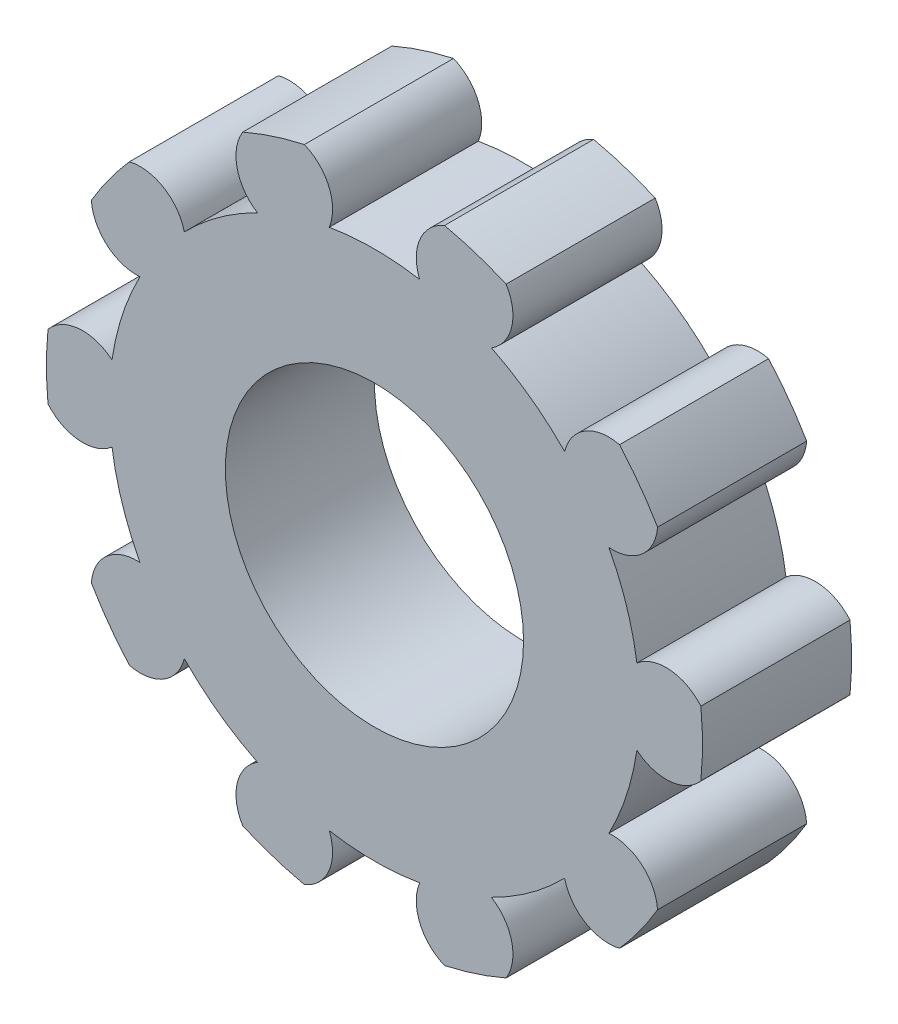
from build123d import *

# Parameters (mm, degrees)
SKETCH1_R           = 13.2
SKETCH1_R_2         = 6
BOSS_EXTRUDE1_DEPTH = 6
CUT_EXTRUDE1_DEPTH  = 7
CIRPATTERN1_COUNT   = 10


with BuildPart() as part:
    # Sketch1 → Boss-Extrude1 (new body)
    with BuildSketch(Plane.XY):
        Circle(SKETCH1_R)
        Circle(SKETCH1_R_2, mode=Mode.SUBTRACT)
    extrude(amount=BOSS_EXTRUDE1_DEPTH)

    # Sketch2 → Cut-Extrude1 (cut, through all)
    with BuildSketch(Plane.XY.offset(6)):
        with BuildLine():
            ThreePointArc((-2.819851171, 12.895287487), (0, 13.2), (2.819851171, 12.895287487))
            ThreePointArc((2.819851171, 12.895287487), (1.826256171, 11.910750525), (1.819851171, 10.512))
            ThreePointArc((1.819851171, 10.512), (0, 10.668364555), (-1.819851171, 10.512))
            ThreePointArc((-1.819851171, 10.512), (-1.826256171, 11.910750525), (-2.819851171, 12.895287487))
        make_face()
    cut_extrude1 = extrude(amount=-CUT_EXTRUDE1_DEPTH, mode=Mode.SUBTRACT)

    # CirPattern1: Cut-Extrude1 ×10 about axis
    cirpattern1_axis = Axis((0, 0, 0), (0, 0, 1))
    for i in range(1, CIRPATTERN1_COUNT):
        add(cut_extrude1.rotate(cirpattern1_axis, i * 360 / CIRPATTERN1_COUNT), mode=Mode.SUBTRACT)


solid = part.part
